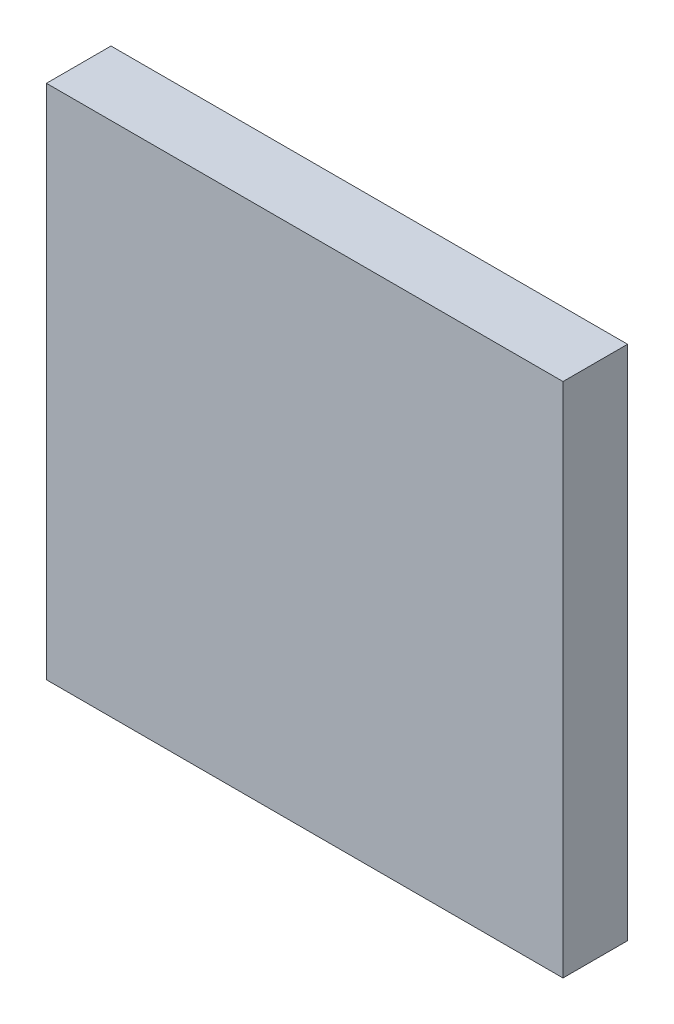
from build123d import *

# Parameters (mm, degrees)
SKETCH_1_W      = 40
SKETCH_1_H      = 40
EXTRUDE_1_DEPTH = 5


with BuildPart() as part:
    # 草图1 → 凸台-拉伸1 (new body)
    with BuildSketch(Plane.XY):
        with Locations((20, 20)):
            Rectangle(SKETCH_1_W, SKETCH_1_H)
    extrude(amount=EXTRUDE_1_DEPTH)


solid = part.part
